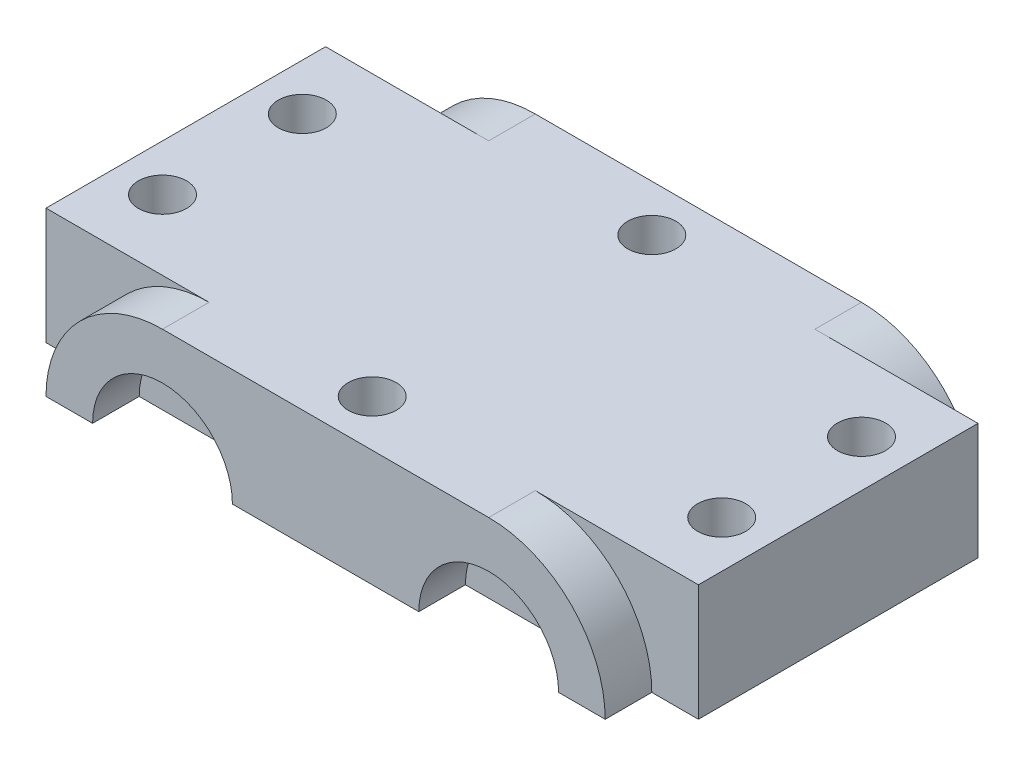
from build123d import *

# Parameters (mm, degrees)
SKETCH2_W           = 177.8
SKETCH2_H           = 31.75
BASE_BLUE_DEPTH     = 76.2
BASE_YELLOW_R_DEPTH = 12.7
BASE_YELLOW_L_DEPTH = 12.7
SKETCH3_R           = 6.5532
CYL_RED_DEPTH       = 32.75


with BuildPart() as part:
    # Sketch2 → base-blue (new body)
    with BuildSketch(Plane.XY):
        Rectangle(SKETCH2_W, SKETCH2_H)
    extrude(amount=-BASE_BLUE_DEPTH)

    # Sketch4 → base-yellow-R (add)
    with BuildSketch(Plane.XY):
        with BuildLine():
            Line((44.45, 15.875), (-44.45, 15.875))
            ThreePointArc((-44.45, 15.875), (-66.900640303, 6.575640303), (-76.2, -15.875))
            Line((-76.2, -15.875), (-63.5, -15.875))
            ThreePointArc((-63.5, -15.875), (-44.45, 3.175), (-25.4, -15.875))
            Line((-25.4, -15.875), (25.4, -15.875))
            ThreePointArc((25.4, -15.875), (44.45, 3.175), (63.5, -15.875))
            Line((63.5, -15.875), (76.2, -15.875))
            ThreePointArc((76.2, -15.875), (66.900640303, 6.575640303), (44.45, 15.875))
        make_face()
    extrude(amount=BASE_YELLOW_R_DEPTH)

    # Sketch5 → base-yellow-L (add)
    with BuildSketch(Plane(origin=(0, 0, -76.2), x_dir=(-1, 0, 0), z_dir=(0, 0, -1))):
        with BuildLine():
            Line((76.2, -15.875), (63.5, -15.875))
            ThreePointArc((63.5, -15.875), (44.45, 3.175), (25.4, -15.875))
            Line((25.4, -15.875), (-25.4, -15.875))
            ThreePointArc((-25.4, -15.875), (-44.45, 3.175), (-63.5, -15.875))
            Line((-63.5, -15.875), (-76.2, -15.875))
            ThreePointArc((-76.2, -15.875), (-66.900640303, 6.575640303), (-44.45, 15.875))
            Line((-44.45, 15.875), (44.45, 15.875))
            ThreePointArc((44.45, 15.875), (66.900640303, 6.575640303), (76.2, -15.875))
        make_face()
    extrude(amount=BASE_YELLOW_L_DEPTH)

    # Sketch3 → cyl-red (cut, through all)
    with BuildSketch(Plane(origin=(0, 15.875, 0), x_dir=(1, 0, 0), z_dir=(0, 1, 0))):
        with Locations((-76.2, 19.05)):
            Circle(SKETCH3_R)
        with Locations((-76.2, 57.15)):
            Circle(SKETCH3_R)
        with Locations((76.2, 57.15)):
            Circle(SKETCH3_R)
        with Locations((76.2, 19.05)):
            Circle(SKETCH3_R)
        Circle(SKETCH3_R)
        with Locations((0, 76.2)):
            Circle(SKETCH3_R)
    extrude(amount=-CYL_RED_DEPTH, mode=Mode.SUBTRACT)


solid = part.part
